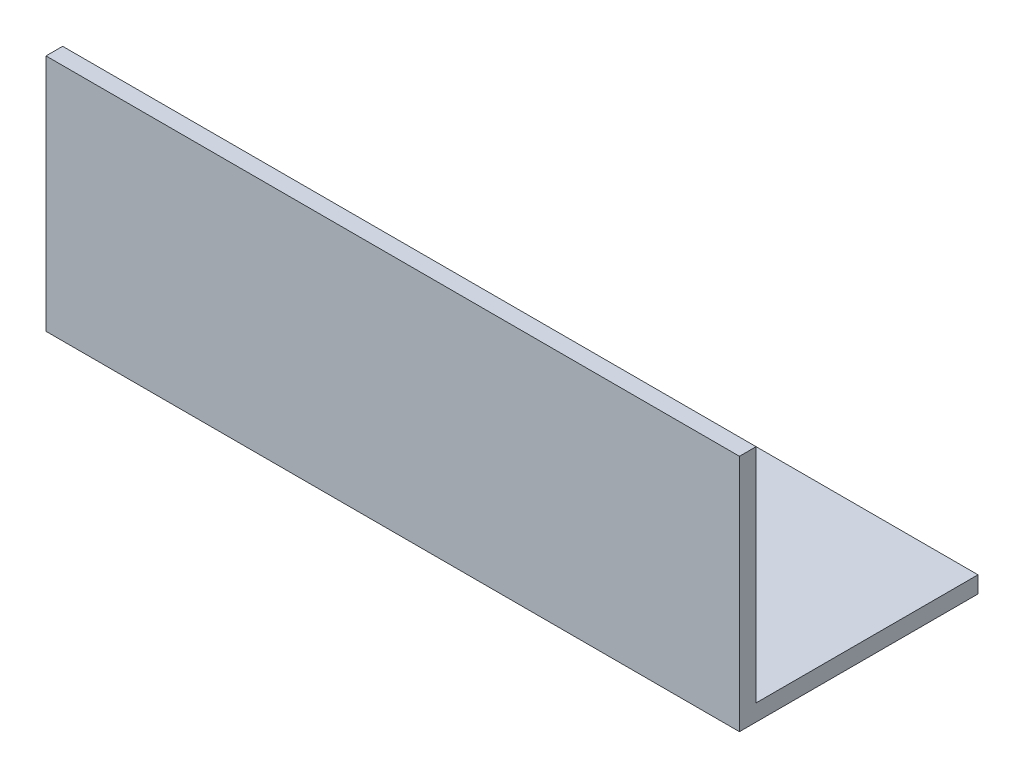
from build123d import *

# Parameters (mm, degrees)
EXTRUDE_1_DEPTH = 125


with BuildPart() as part:
    # Эскиз1 → Вытянуть-Тонкостенный1 (new body)
    with BuildSketch(Plane(origin=(0, 0, 0), x_dir=(0, 0, -1), z_dir=(1, 0, 0))):
        Polygon((0, 40), (0, 0), (40, 0), (40, -3), (-3, -3), (-3, 40), align=None)
    extrude(amount=EXTRUDE_1_DEPTH)


solid = part.part
